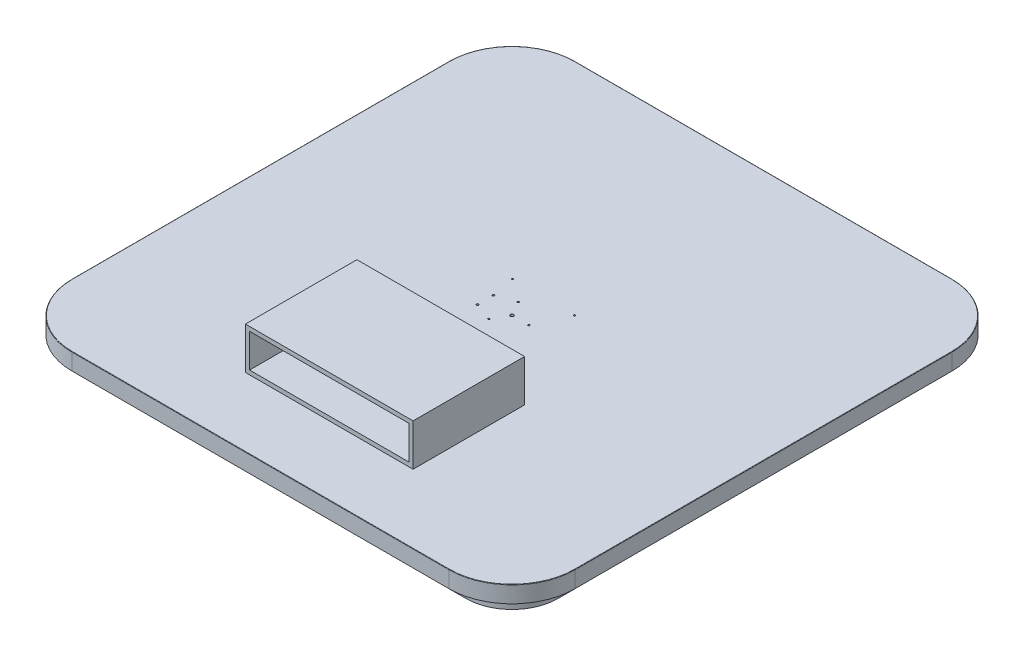
from build123d import *

# Parameters (mm, degrees)
BOSS_EXTRUDE1_DEPTH    = 40
BOSS_EXTRUDE2_DEPTH    = 40
SKETCH3_W              = 200
SKETCH3_H              = 200
CUT_EXTRUDE1_DEPTH     = 6.35
SKETCH4_R              = 2.4892
SKETCH4_R_2            = 3.96875
CUT_EXTRUDE2_DEPTH     = 81
F_10_32_TAPPED_HOLE1_D = 4.0386
SKETCH10_R             = 2.02
SKETCH10_R_2           = 2.032
CUT_EXTRUDE3_DEPTH     = 81
SKETCH11_W             = 200
SKETCH11_H             = 50
CUT_EXTRUDE4_DEPTH     = 81
FILLET1_R              = 1
SKETCH12_W             = 400
SKETCH12_H             = 266
BOSS_EXTRUDE3_DEPTH    = 100
SKETCH13_W             = 380
SKETCH13_H             = 80
CUT_EXTRUDE5_DEPTH     = 266
CUT_EXTRUDE6_DEPTH     = 6.35


with BuildPart() as part:
    # Sketch1 → Boss-Extrude1 (new body)
    with BuildSketch(Plane(origin=(0, 0, 0), x_dir=(1, 0, 0), z_dir=(0, 1, 0))):
        with BuildLine():
            Line((-450, -600), (450, -600))
            ThreePointArc((450, -600), (556.066017178, -556.066017178), (600, -450))
            Line((600, -450), (600, 450))
            ThreePointArc((600, 450), (556.066017178, 556.066017178), (450, 600))
            Line((450, 600), (-450, 600))
            ThreePointArc((-450, 600), (-556.066017178, 556.066017178), (-600, 450))
            Line((-600, 450), (-600, -450))
            ThreePointArc((-600, -450), (-556.066017178, -556.066017178), (-450, -600))
        make_face()
    extrude(amount=BOSS_EXTRUDE1_DEPTH)

    # Sketch2 → Boss-Extrude2 (add)
    with BuildSketch(Plane.XZ):
        with BuildLine():
            Line((560, -450), (560, 450))
            ThreePointArc((560, 450), (527.781745931, 527.781745931), (450, 560))
            Line((450, 560), (-450, 560))
            ThreePointArc((-450, 560), (-527.781745931, 527.781745931), (-560, 450))
            Line((-560, 450), (-560, -450))
            ThreePointArc((-560, -450), (-527.781745931, -527.781745931), (-450, -560))
            Line((-450, -560), (450, -560))
            ThreePointArc((450, -560), (527.781745931, -527.781745931), (560, -450))
        make_face()
    extrude(amount=BOSS_EXTRUDE2_DEPTH)

    # Sketch3 → Cut-Extrude1 (cut)
    with BuildSketch(Plane.XZ.offset(40)):
        Rectangle(SKETCH3_W, SKETCH3_H)
    extrude(amount=-CUT_EXTRUDE1_DEPTH, mode=Mode.SUBTRACT)

    # Sketch4 → Cut-Extrude2 (cut, through all)
    with BuildSketch(Plane(origin=(0, -40, 0), x_dir=(-1, 0, 0), z_dir=(0, -1, 0))):
        with Locations((63.487218193, 19.092554208)):
            Circle(SKETCH4_R)
        with Locations((63.512753284, -19.007437235)):
            Circle(SKETCH4_R)
        Circle(SKETCH4_R_2)
    extrude(amount=-CUT_EXTRUDE2_DEPTH, mode=Mode.SUBTRACT)

    # #10-32 Tapped Hole1 (through all)
    with Locations(Plane(origin=(0, -40, 0), x_dir=(-1, 0, 0), z_dir=(0, -1, 0))):
        with Locations((20.137841448, 34.93381382), (-40.322490944, -0.027024638), (20.184649496, -34.906789182)):
            Hole(F_10_32_TAPPED_HOLE1_D / 2)

    # Sketch10 → Cut-Extrude3 (cut, through all)
    with BuildSketch(Plane(origin=(0, -40, 0), x_dir=(-1, 0, 0), z_dir=(0, -1, 0))):
        with Locations((-74.649981089, 74.549985402)):
            Circle(SKETCH10_R)
        with Locations((74.549274576, 75.710578627)):
            Circle(SKETCH10_R)
        with Locations((74.649981089, -74.549985402)):
            Circle(SKETCH10_R)
        with Locations((-74.549985402, -74.649981089)):
            Circle(SKETCH10_R_2)
    extrude(amount=-CUT_EXTRUDE3_DEPTH, mode=Mode.SUBTRACT)

    # Sketch11 → Cut-Extrude4 (cut, through all)
    with BuildSketch(Plane(origin=(0, -40, 0), x_dir=(-1, 0, 0), z_dir=(0, -1, 0))):
        with Locations((0, -145)):
            Rectangle(SKETCH11_W, SKETCH11_H)
    extrude(amount=-CUT_EXTRUDE4_DEPTH, mode=Mode.SUBTRACT)

    # Fillet1
    fillet1_edges = [part.edges().sort_by_distance(p)[0] for p in [
        (-556.066017178, 40, -556.066017178),
        (-600, 40, 0),
        (-556.066017178, 40, 556.066017178),
        (0, 40, 600),
        (556.066017178, 40, 556.066017178),
        (600, 40, 0),
        (556.066017178, 40, -556.066017178),
        (0, 40, -600),
    ]]
    fillet(fillet1_edges, radius=FILLET1_R)

    # Sketch12 → Boss-Extrude3 (add)
    with BuildSketch(Plane(origin=(0, 40, 0), x_dir=(1, 0, 0), z_dir=(0, 1, 0))):
        with Locations((0, -303)):
            Rectangle(SKETCH12_W, SKETCH12_H)
    extrude(amount=BOSS_EXTRUDE3_DEPTH)

    # Sketch13 → Cut-Extrude5 (cut)
    with BuildSketch(Plane.XY.offset(436)):
        with Locations((0, 90)):
            Rectangle(SKETCH13_W, SKETCH13_H)
    extrude(amount=-CUT_EXTRUDE5_DEPTH, mode=Mode.SUBTRACT)

    # Sketch14 → Cut-Extrude6 (cut)
    with BuildSketch(Plane(origin=(0, -40, 0), x_dir=(-1, 0, 0), z_dir=(0, -1, 0))):
        with BuildLine():
            Line((-450, -535), (-295, -535))
            Line((-295, -535), (-295, -295))
            Line((-295, -295), (-535, -295))
            Line((-535, -295), (-535, -450))
            ThreePointArc((-535, -450), (-510.104076401, -510.104076401), (-450, -535))
        make_face()
    extrude(amount=-CUT_EXTRUDE6_DEPTH, mode=Mode.SUBTRACT)


solid = part.part
